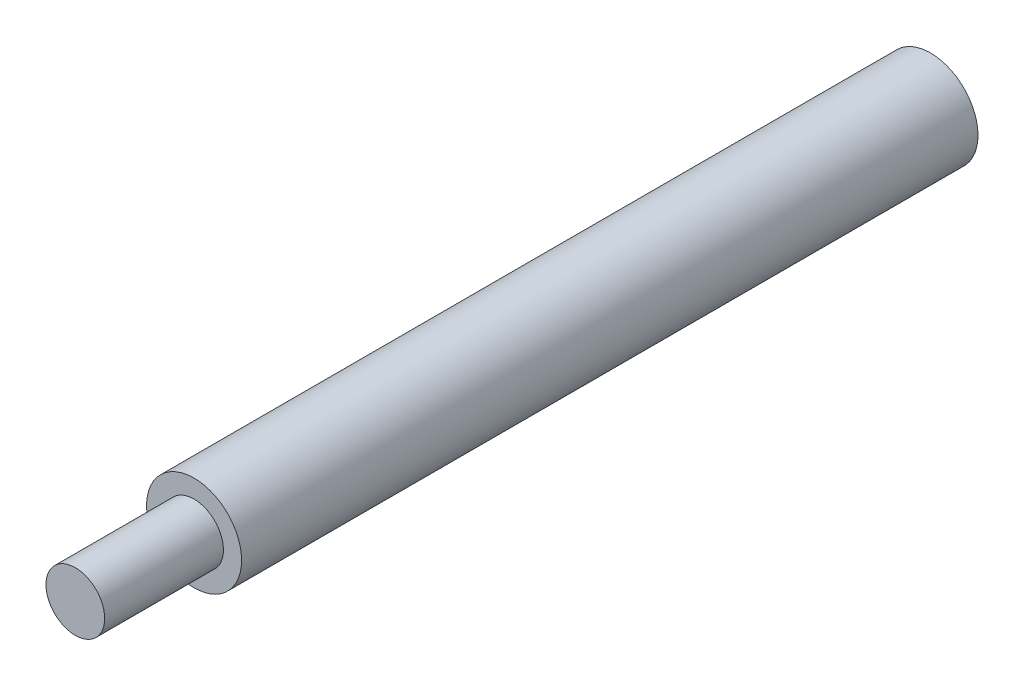
from build123d import *

# Parameters (mm, degrees)
SKETCH1_R           = 4
BOSS_EXTRUDE1_DEPTH = 62
SKETCH2_R           = 2.471690238
BOSS_EXTRUDE2_DEPTH = 10


with BuildPart() as part:
    # Sketch1 → Boss-Extrude1 (new body)
    with BuildSketch(Plane.XY):
        Circle(SKETCH1_R)
    extrude(amount=BOSS_EXTRUDE1_DEPTH)

    # Sketch2 → Boss-Extrude2 (add)
    with BuildSketch(Plane.XY.offset(62)):
        Circle(SKETCH2_R)
    extrude(amount=BOSS_EXTRUDE2_DEPTH)


solid = part.part
